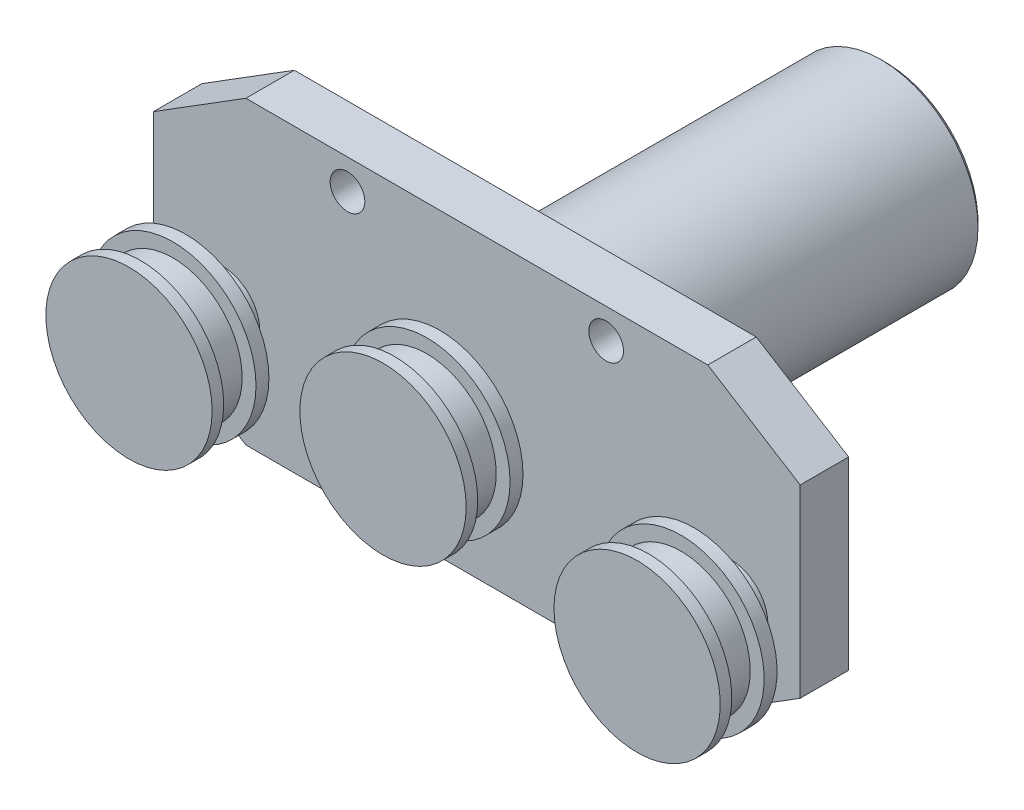
from build123d import *

# Parameters (mm, degrees)
SKETCH1_W           = 20
SKETCH1_H           = 40
SKETCH1_W_2         = 50
SKETCH1_H_2         = 65
SKETCH1_R           = 2.25
BOSS_EXTRUDE1_DEPTH = 10.5
SKETCH3_R           = 6.5
SKETCH3_R_2         = 8
BOSS_EXTRUDE2_DEPTH = 8
SKETCH4_R           = 3.75
CUT_EXTRUDE1_DEPTH  = 6
SKETCH5_R           = 18
BOSS_EXTRUDE3_DEPTH = 12.3
SKETCH7_W           = 167.229187532
SKETCH7_H           = 99.836007656
SKETCH7_R           = 15
CUT_EXTRUDE2_DEPTH  = 7
SKETCH8_R           = 21
BOSS_EXTRUDE4_DEPTH = 78
CHAMFER1_SIZE       = 1
SKETCH9_R           = 2
BOSS_EXTRUDE5_DEPTH = 3


with BuildPart() as part:
    # Sketch1 → Boss-Extrude1 (new body)
    with BuildSketch(Plane.XY):
        Polygon((-25, -20), (-45, -20), (-25, -32.5), align=None)
        with Locations((-35, 0)):
            Rectangle(SKETCH1_W, SKETCH1_H)
        Polygon((-25, 20), (-25, 32.5), (-45, 20), align=None)
        Rectangle(SKETCH1_W_2, SKETCH1_H_2)
        with Locations((-3, 26)):
            Circle(SKETCH1_R, mode=Mode.SUBTRACT)
        with Locations((-3, -26)):
            Circle(SKETCH1_R, mode=Mode.SUBTRACT)
    boss_extrude1 = extrude(amount=BOSS_EXTRUDE1_DEPTH)

    # Mirror1: Boss-Extrude1 across plane
    add(boss_extrude1.mirror(Plane(origin=(25, 0, 10.5), x_dir=(0, 0, 1), z_dir=(1, 0, 0))))

    # Sketch3 → Boss-Extrude2 (add)
    with BuildSketch(Plane.XY.offset(10.5)):
        with Locations((25, 0)):
            Circle(SKETCH3_R)
        with Locations((-30, -9.5)):
            Circle(SKETCH3_R_2)
        with Locations((80, -9.5)):
            Circle(SKETCH3_R_2)
    extrude(amount=BOSS_EXTRUDE2_DEPTH)

    # Sketch4 → Cut-Extrude1 (cut)
    with BuildSketch(Plane.XY.offset(10.5)):
        with Locations((-3, -26)):
            Circle(SKETCH4_R)
        with Locations((-3, 26)):
            Circle(SKETCH4_R)
        with Locations((53, 26)):
            Circle(SKETCH4_R)
        with Locations((53, -26)):
            Circle(SKETCH4_R)
    extrude(amount=-CUT_EXTRUDE1_DEPTH, mode=Mode.SUBTRACT)

    # Sketch5 → Boss-Extrude3 (add)
    with BuildSketch(Plane.XY.offset(18.5)):
        with Locations((25, 0)):
            Circle(SKETCH5_R)
        with Locations((-30, -9.5)):
            Circle(SKETCH5_R)
    extrude(amount=BOSS_EXTRUDE3_DEPTH)

    # Sketch7 → Cut-Extrude2 (cut)
    with BuildSketch(Plane.XY.offset(28.3)):
        with Locations((-30, -9.5)):
            Rectangle(SKETCH7_W, SKETCH7_H)
        with Locations((-30, -9.5)):
            Circle(SKETCH7_R, mode=Mode.SUBTRACT)
        with Locations((25, 0)):
            Circle(SKETCH7_R, mode=Mode.SUBTRACT)
    extrude(amount=-CUT_EXTRUDE2_DEPTH, mode=Mode.SUBTRACT)

    # Mirror2: part across plane


with BuildPart() as part_1:
    add(part.part)
    add(part.part.mirror(Plane(origin=(25, 0, 0), x_dir=(0, 0, 1), z_dir=(1, 0, 0))))

    # Sketch8 → Boss-Extrude4 (add)
    with BuildSketch(Plane(origin=(0, 0, 0), x_dir=(-1, 0, 0), z_dir=(0, 0, -1))):
        with Locations((-25, 0)):
            Circle(SKETCH8_R)
    extrude(amount=BOSS_EXTRUDE4_DEPTH)

    # Chamfer1
    chamfer1_edges = [part_1.edges().sort_by_distance(p)[0] for p in [
        (46, 0, -78),
    ]]
    chamfer(chamfer1_edges, length=CHAMFER1_SIZE)

    # Sketch9 → Boss-Extrude5 (add, symmetric)
    with BuildSketch(Plane(origin=(0, 0, 0), x_dir=(-1, 0, 0), z_dir=(0, 0, -1))):
        with Locations((-80, -9.5)):
            Circle(SKETCH9_R)
        with Locations((30, -9.5)):
            Circle(SKETCH9_R)
    extrude(amount=BOSS_EXTRUDE5_DEPTH, both=True)


solid = part_1.part
